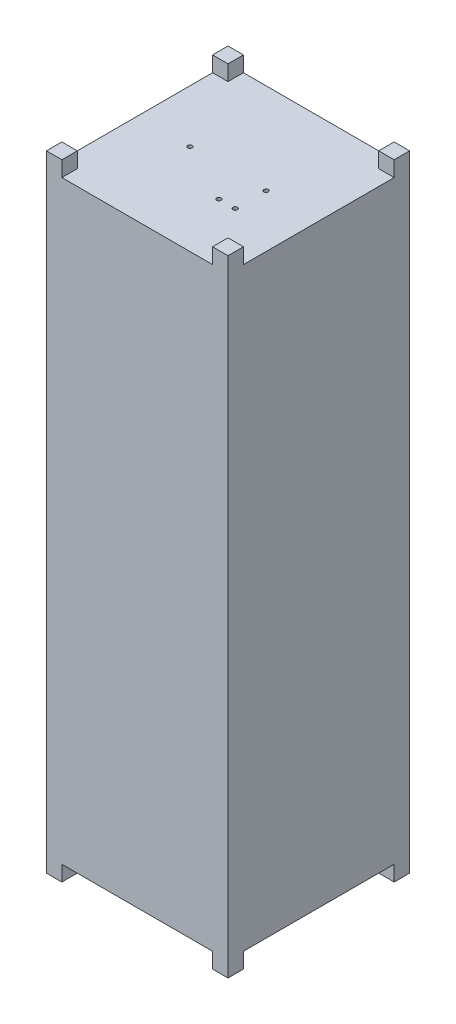
from build123d import *

# Parameters (mm, degrees)
BOSS_EXTRUDE1_DEPTH      = 327.5
SKETCH30_R               = 1.2
CUT_EXTRUDE4_DEPTH       = 10
SKETCH31_W               = 8.5
SKETCH31_H               = 8.5
BOSS_EXTRUDE2_DEPTH      = 8.5
BOSS_EXTRUDE2_DEPTH_BACK = 336


with BuildPart() as part:
    # Sketch1 → Boss-Extrude1 (new body)
    with BuildSketch(Plane(origin=(0, 0, 0), x_dir=(1, 0, 0), z_dir=(0, 1, 0))):
        Polygon((0, 17), (0, 0), (17, 0), (83, 0), (100, 0), (100, 17), (100, 83), (100, 100), (83, 100), (17, 100), (0, 100), (0, 83), align=None)
    extrude(amount=-BOSS_EXTRUDE1_DEPTH)

    # Sketch30 → Cut-Extrude4 (cut)
    with BuildSketch(Plane(origin=(0, 0, 0), x_dir=(-1, 0, 0), z_dir=(0, 1, 0))):
        with Locations((-71, -50)):
            Circle(SKETCH30_R)
        with Locations((-29, -50)):
            Circle(SKETCH30_R)
        with Locations((-62, -33)):
            Circle(SKETCH30_R)
        with Locations((-71, -33)):
            Circle(SKETCH30_R)
    extrude(amount=-CUT_EXTRUDE4_DEPTH, mode=Mode.SUBTRACT)

    # Sketch31 → Boss-Extrude2 (add, two sides)
    with BuildSketch(Plane(origin=(0, -327.5, 0), x_dir=(-1, 0, 0), z_dir=(0, -1, 0))) as boss_extrude2_sk:
        with Locations((-4.25, 95.75)):
            Rectangle(SKETCH31_W, SKETCH31_H)
        with Locations((-95.75, 95.75)):
            Rectangle(SKETCH31_W, SKETCH31_H)
        with Locations((-4.25, 4.25)):
            Rectangle(SKETCH31_W, SKETCH31_H)
        with Locations((-95.75, 4.25)):
            Rectangle(SKETCH31_W, SKETCH31_H)
    extrude(amount=BOSS_EXTRUDE2_DEPTH)
    extrude(boss_extrude2_sk.sketch, amount=-BOSS_EXTRUDE2_DEPTH_BACK)


solid = part.part
